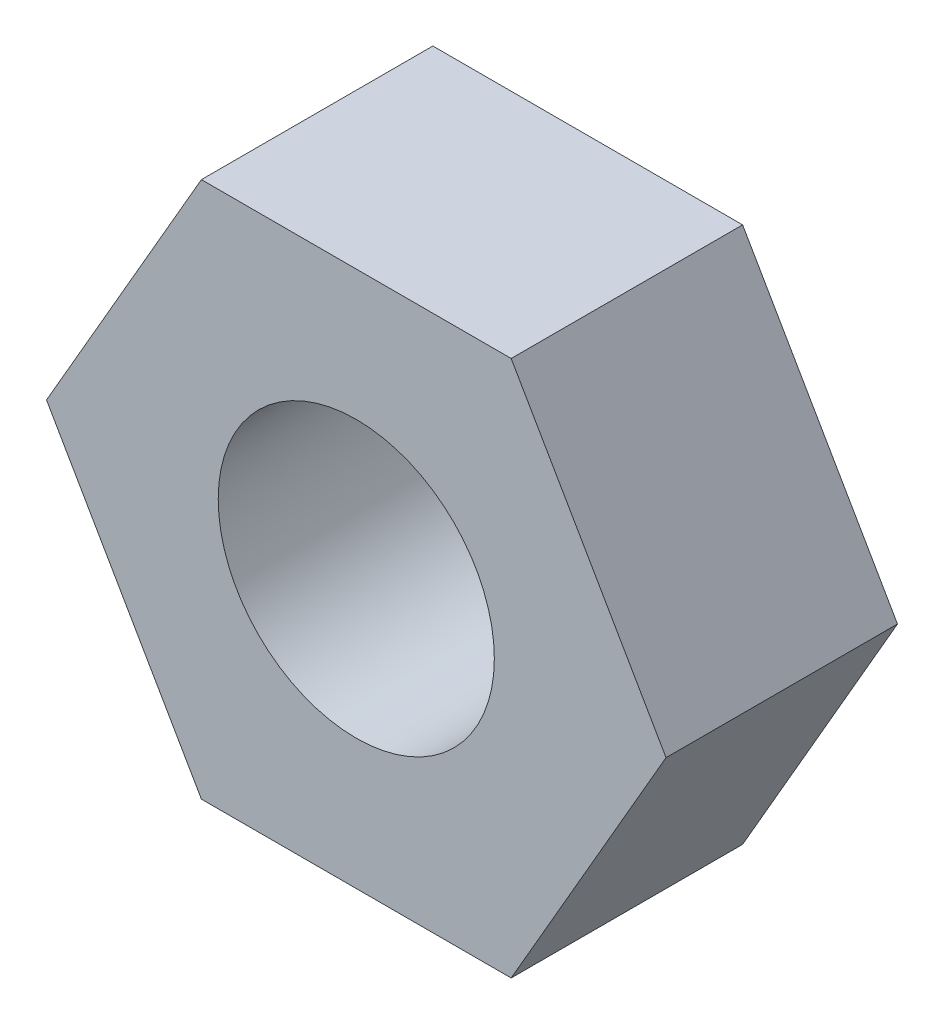
from build123d import *

# Parameters (mm, degrees)
SKETCH1_R           = 1
BOSS_EXTRUDE1_DEPTH = 1.6764


with BuildPart() as part:
    # Sketch1 → Boss-Extrude1 (new body)
    with BuildSketch(Plane.XY):
        Polygon((2.243698616, 0), (1.121849308, 1.9431), (-1.121849308, 1.9431), (-2.243698616, 0), (-1.121849308, -1.9431), (1.121849308, -1.9431), align=None)
        Circle(SKETCH1_R, mode=Mode.SUBTRACT)
    extrude(amount=BOSS_EXTRUDE1_DEPTH)


solid = part.part
